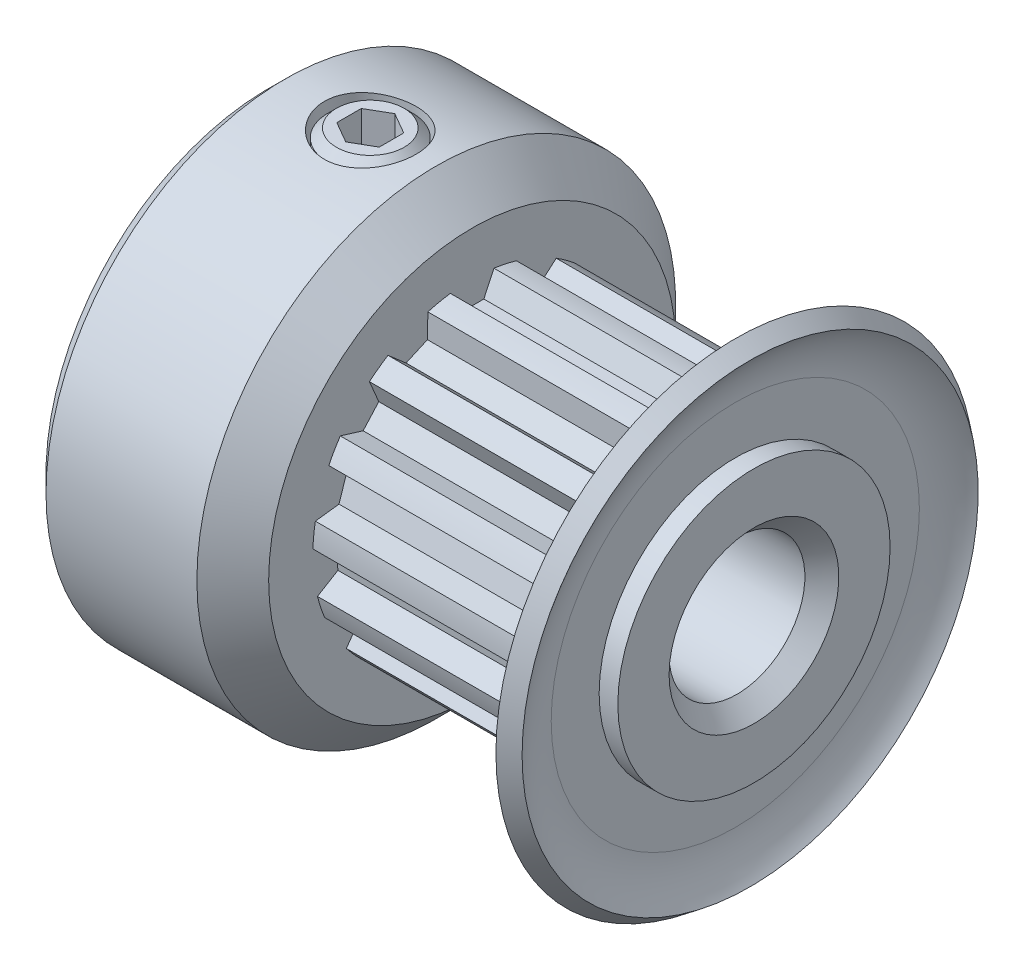
from build123d import *

# Parameters (mm, degrees)
SKETCH4_R          = 4.85
SKETCH4_R_2        = 4.69125
CUT_EXTRUDE2_DEPTH = 7.2
CUT_EXTRUDE1_DEPTH = 7.2
CIRPATTERN1_COUNT  = 15
SKETCH6_R          = 1.35
CUT_EXTRUDE3_DEPTH = 13.268964912
CUT_EXTRUDE4_DEPTH = 1.016
CHAMFER1_SIZE      = 0.5


with BuildPart() as part:
    # Sketch1 → Revolve1 (revolve)
    with BuildSketch(Plane.XY, mode=Mode.PRIVATE) as revolve1_sk:
        with BuildLine():
            Line((-7.15, 2), (7.15, 2))
            Line((7.15, 2), (7.15, 7.05))
            Line((7.15, 7.05), (6.6, 7.05))
            ThreePointArc((6.6, 7.05), (6.191212109, 6.280934734), (6.05, 5.4215))
            Line((6.05, 5.4215), (6.05, 4.85))
            Line((6.05, 4.85), (-1.15, 4.85))
            Line((-1.15, 4.85), (-1.15, 5.993))
            Line((-1.15, 5.993), (-2.207, 7.05))
            Line((-2.207, 7.05), (-7.15, 7.05))
            Line((-7.15, 7.05), (-7.15, 2))
        make_face()
    revolve(revolve1_sk.sketch.rotate(Axis((-7.15, 0, 0), (1, 0, 0)), 90), axis=Axis((-7.15, 0, 0), (1, 0, 0)))

    # Sketch4 → Cut-Extrude2 (cut)
    with BuildSketch(Plane(origin=(-1.15, 0, 0), x_dir=(0, 0, -1), z_dir=(1, 0, 0))):
        Circle(SKETCH4_R)
        Circle(SKETCH4_R_2, mode=Mode.SUBTRACT)
    extrude(amount=CUT_EXTRUDE2_DEPTH, mode=Mode.SUBTRACT)

    # Sketch3 → Cut-Extrude1 (cut)
    with BuildSketch(Plane(origin=(-1.15, 0, 0), x_dir=(0, 0, -1), z_dir=(1, 0, 0))):
        with BuildLine():
            Line((-0.641824768, 4.647137563), (-0.344592193, 4.009720248))
            Line((-0.344592193, 4.009720248), (0.344592193, 4.009720248))
            Line((0.344592193, 4.009720248), (0.641824768, 4.647137563))
            ThreePointArc((0.641824768, 4.647137563), (0, 4.69125), (-0.641824768, 4.647137563))
        make_face()
    cut_extrude1 = extrude(amount=CUT_EXTRUDE1_DEPTH, mode=Mode.SUBTRACT)

    # CirPattern1: Cut-Extrude1 ×15 about axis
    cirpattern1_axis = Axis((0, 0, 0), (1, 0, 0))
    for i in range(1, CIRPATTERN1_COUNT):
        add(cut_extrude1.rotate(cirpattern1_axis, i * 360 / CIRPATTERN1_COUNT), mode=Mode.SUBTRACT)

    # Sketch6 → Cut-Extrude3 (cut, through all)
    with BuildSketch(Plane(origin=(0, 0, 0), x_dir=(1, 0, 0), z_dir=(0, 1, 0))):
        with Locations(Location((-4.15, 0, 0), (0, 0, 90))):
            Circle(SKETCH6_R)
    extrude(amount=CUT_EXTRUDE3_DEPTH, mode=Mode.SUBTRACT)

    # Chamfer1
    chamfer1_edges = [part.edges().sort_by_distance(p)[0] for p in [
        (-7.15, 0, -7.05),
        (-7.15, 0, -2),
        (7.15, 0, -2),
    ]]
    chamfer(chamfer1_edges, length=CHAMFER1_SIZE)

    # Sketch9 → Cut-Revolve1 (revolve, cut)
    with BuildSketch(Plane.XY, mode=Mode.PRIVATE) as cut_revolve1_sk:
        with BuildLine():
            Line((7.15, 4.009720248), (7.15, 7.05))
            Line((7.15, 7.05), (6.802186426, 7.315185187))
            Line((6.802186426, 7.315185187), (6.6, 7.05))
            Line((6.6, 7.05), (7.037375657, 6.71652956))
            ThreePointArc((7.037375657, 6.71652956), (6.712295889, 6.104946967), (6.6, 5.4215))
            Line((6.6, 5.4215), (6.6, 4.009720248))
            Line((6.6, 4.009720248), (7.15, 4.009720248))
        make_face()
    revolve(cut_revolve1_sk.sketch.rotate(Axis((-7.15, 0, 0), (1, 0, 0)), 90), axis=Axis((-7.15, 0, 0), (1, 0, 0)), mode=Mode.SUBTRACT)


with BuildPart() as body_2:
    # Sketch7 → Revolve2 (revolve)
    with BuildSketch(Plane.XY, mode=Mode.PRIVATE) as revolve2_sk:
        Polygon((-5.146, 7.05), (-4.15, 7.05), (-4.15, 2.381), (-5.146, 2.381), (-5.4, 2.635), (-5.4, 6.796), align=None)
    revolve(revolve2_sk.sketch.rotate(Axis((-4.15, 2.381, 0), (0, 1, 0)), 270), axis=Axis((-4.15, 2.381, 0), (0, 1, 0)))

    # Sketch8 → Cut-Extrude4 (cut)
    with BuildSketch(Plane(origin=(0, 7.05, 0), x_dir=(1, 0, 0), z_dir=(0, 1, 0))):
        Polygon((-4.15, 0.721687836), (-4.775, 0.360843918), (-4.775, -0.360843918), (-4.15, -0.721687836), (-3.525, -0.360843918), (-3.525, 0.360843918), align=None)
    extrude(amount=-CUT_EXTRUDE4_DEPTH, mode=Mode.SUBTRACT)


solid = Compound([part.part, body_2.part])
